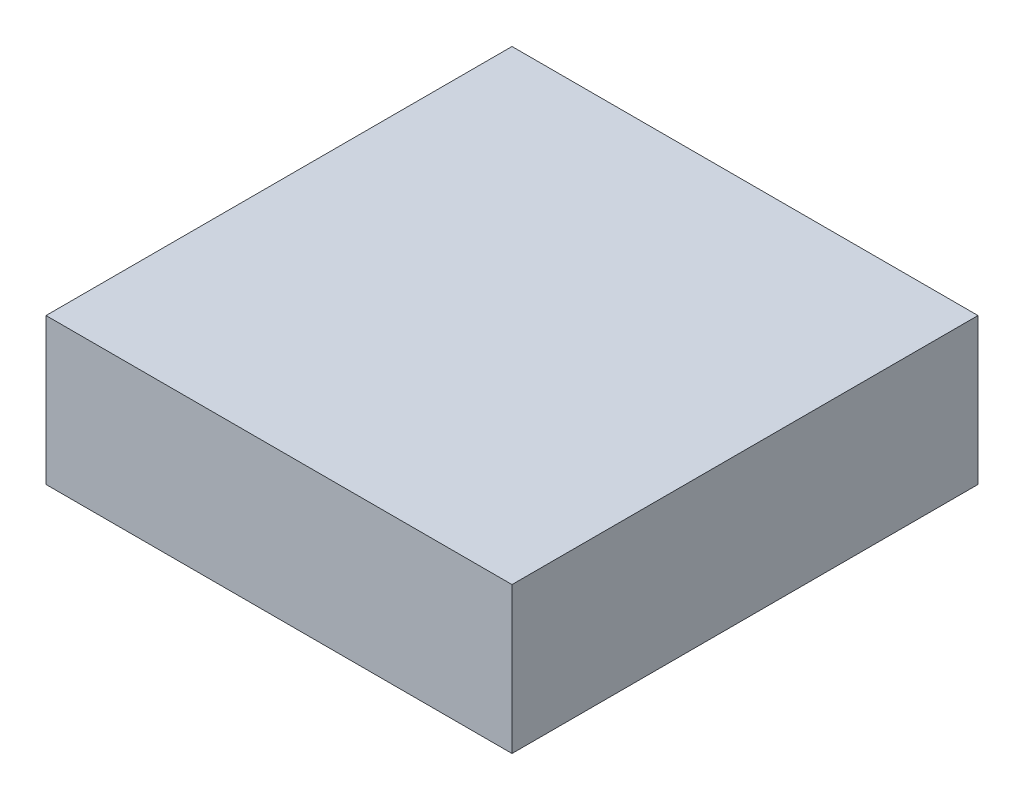
from build123d import *

# Parameters (mm, degrees)
SKETCH1_W           = 5
SKETCH1_H           = 5
BOSS_EXTRUDE1_DEPTH = 1.57


with BuildPart() as part:
    # Sketch1 → Boss-Extrude1 (new body)
    with BuildSketch(Plane(origin=(0, 0, 0), x_dir=(1, 0, 0), z_dir=(0, 1, 0))):
        with Locations((2.5, 2.5)):
            Rectangle(SKETCH1_W, SKETCH1_H)
    extrude(amount=BOSS_EXTRUDE1_DEPTH)


solid = part.part
